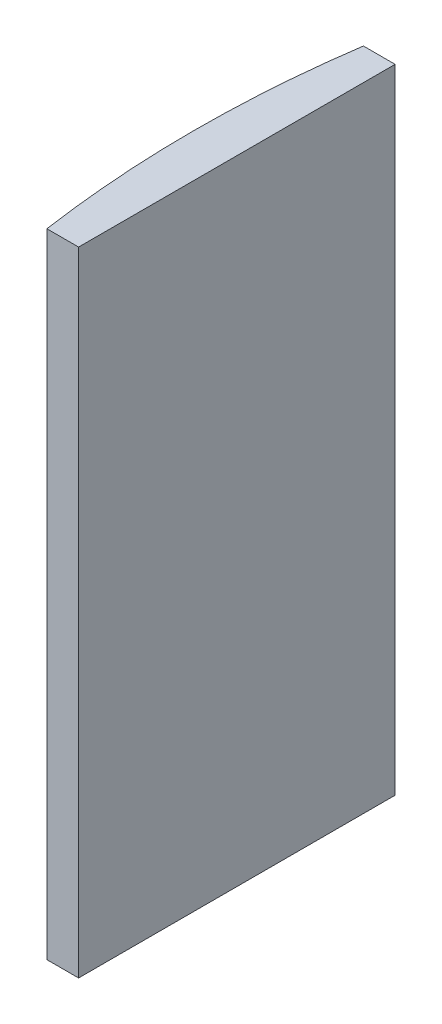
from build123d import *

# Parameters (mm, degrees)
EXTRUDE_1_DEPTH = 60


with BuildPart() as part:
    # 草图1 → 凸台-拉伸1 (new body)
    with BuildSketch(Plane(origin=(0, 0, 0), x_dir=(1, 0, 0), z_dir=(0, 1, 0))):
        with BuildLine():
            Line((-97.95100271, 15), (-94.944795665, 15))
            Line((-94.944795665, 15), (-94.944795665, -15))
            Line((-94.944795665, -15), (-97.95100271, -15))
            ThreePointArc((-97.95100271, -15), (-99.044795665, 0), (-97.95100271, 15))
        make_face()
    extrude(amount=EXTRUDE_1_DEPTH)


solid = part.part
